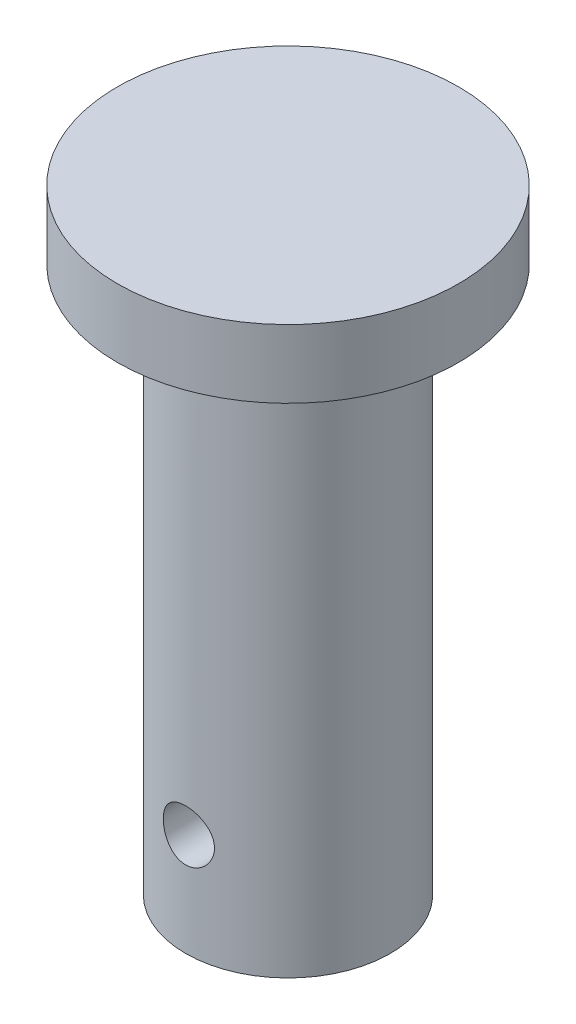
from build123d import *

# Parameters (mm, degrees)
SKETCH2_R          = 1.5
CUT_EXTRUDE1_DEPTH = 7


with BuildPart() as part:
    # Sketch1 → Revolve1 (revolve)
    with BuildSketch(Plane.XY):
        Polygon((0, 0), (6, 0), (6, 32), (10, 32), (10, 36), (0, 36), align=None)
    revolve(axis=Axis((0, 36, 0), (0, -1, 0)))

    # Sketch2 → Cut-Extrude1 (cut, symmetric)
    with BuildSketch(Plane.XY):
        with Locations((0, 6)):
            Circle(SKETCH2_R)
    extrude(amount=CUT_EXTRUDE1_DEPTH, both=True, mode=Mode.SUBTRACT)


solid = part.part
